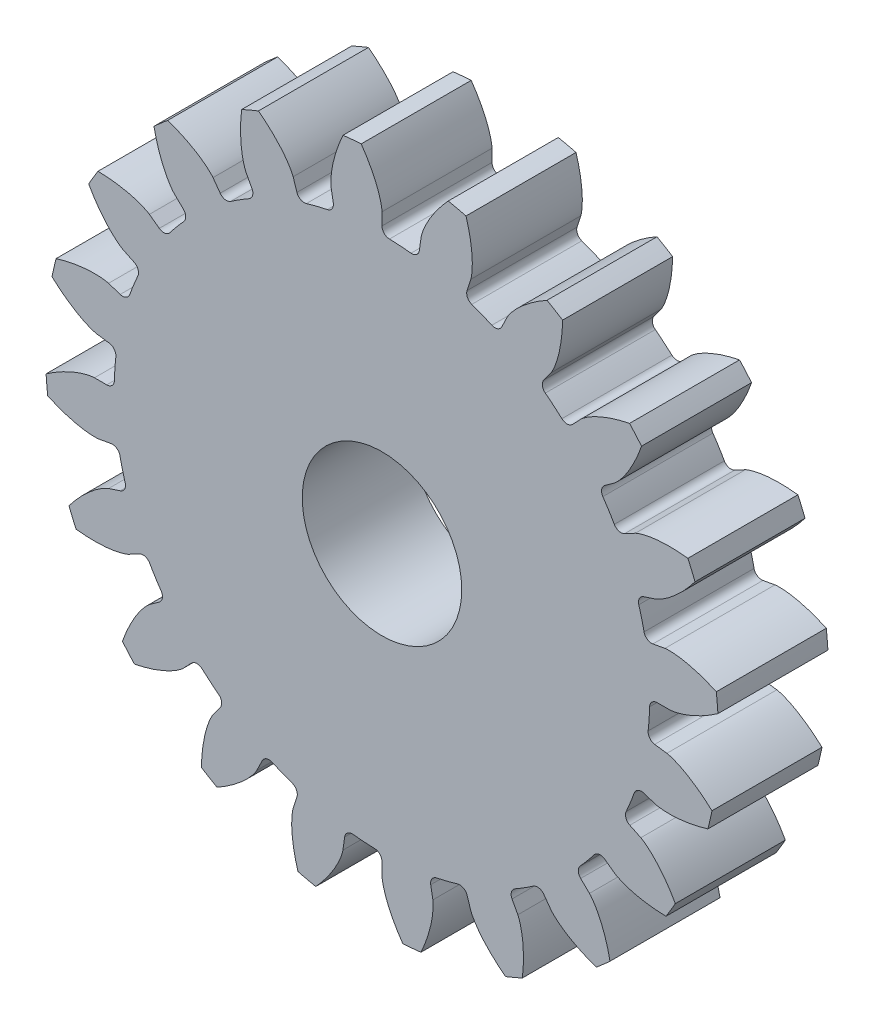
from build123d import *

# Parameters (mm, degrees)
BOSS_EXTRUDE3_DEPTH       = 4
FILLET1_R                 = 0.278125
CIRPATTERN8_COUNT         = 20
CIRPATTERN8_COPY_1_DEPTH  = 4
CIRPATTERN8_COPY_2_DEPTH  = 4
CIRPATTERN8_COPY_3_DEPTH  = 4
CIRPATTERN8_COPY_4_DEPTH  = 4
CIRPATTERN8_COPY_5_DEPTH  = 4
CIRPATTERN8_COPY_6_DEPTH  = 4
CIRPATTERN8_COPY_7_DEPTH  = 4
CIRPATTERN8_COPY_8_DEPTH  = 4
CIRPATTERN8_COPY_9_DEPTH  = 4
CIRPATTERN8_COPY_10_DEPTH = 4
CIRPATTERN8_COPY_11_DEPTH = 4
CIRPATTERN8_COPY_12_DEPTH = 4
CIRPATTERN8_COPY_13_DEPTH = 4
CIRPATTERN8_COPY_14_DEPTH = 4
CIRPATTERN8_COPY_15_DEPTH = 4
CIRPATTERN8_COPY_16_DEPTH = 4
CIRPATTERN8_COPY_17_DEPTH = 4
CIRPATTERN8_COPY_18_DEPTH = 4
CIRPATTERN8_COPY_19_DEPTH = 4
FILLET1_OF_CIRPATTERN8_R  = 0.278125
SKETCH3_R                 = 2.9
CUT_EXTRUDE2_DEPTH        = 5.0000001


with BuildPart() as part:
    # Sketch1 → Boss-Extrude3 (new body)
    with BuildSketch(Plane.XY):
        with BuildLine():
            Line((9.734375, 0), (10.454080406, 0))
            add(Edge.make_bspline(
                [(10.454080406, 0), (10.461809141, 0.000163554), (10.48346946, 0.00112842), (10.524328883, 0.004950284), (10.590725843, 0.014014033), (10.674812946, 0.0297017), (10.782700919, 0.054699934), (10.908582693, 0.090177148), (11.045409754, 0.135423901), (11.192393304, 0.191325941), (11.337182026, 0.252938931), (11.479722698, 0.319767641), (11.619896721, 0.391139023), (11.787363934, 0.483173443), (11.953826699, 0.582713105), (12.083883515, 0.667078153), (12.179202273, 0.732235691), (12.21409259, 0.756537141)],
                knots=[0, 0, 0, 0, 0, 0.005376748, 0.015083688, 0.02853182, 0.046610139, 0.064854849, 0.092110525, 0.119476175, 0.146842495, 0.174208853, 0.201574955, 0.228941013, 0.256307345, 0.307035032, 0.336624535, 0.336624535, 0.336624535, 0.336624535, 0.336624535], degree=4))
            ThreePointArc((12.21409259, 0.756537141), (12.202725609, 0.921896939), (12.189120016, 1.087087613))
            Line((12.189120016, 1.087087613), (9.695890922, 0.864728783))
            ThreePointArc((9.695890922, 0.864728783), (9.724749221, 0.432792356), (9.734375, 0))
        make_face()
        with BuildLine():
            ThreePointArc((-9.695890922, -0.864728783), (0.432792356, -9.724749221), (9.734375, 0))
            ThreePointArc((9.734375, 0), (9.724749221, 0.432792356), (9.695890922, 0.864728783))
            Line((9.695890922, 0.864728783), (-9.695890922, -0.864728783))
        make_face()
        with BuildLine():
            Line((-9.695890922, -0.864728783), (9.695890922, 0.864728783))
            ThreePointArc((9.695890922, 0.864728783), (-0.864728783, 9.695890922), (-9.695890922, -0.864728783))
        make_face()
    boss_extrude3 = extrude(amount=BOSS_EXTRUDE3_DEPTH)

    # Mirror2: Boss-Extrude3 across plane
    add(boss_extrude3.mirror(Plane(origin=(0, 0, 4), x_dir=(0, 0, 1), z_dir=(0.088832491, -0.996046579, 0))))

    # Fillet1
    fillet1_edges = [part.edges().sort_by_distance(p)[0] for p in [
        (9.734375, 0, 2),
        (9.580742976, 1.722620293, 2),
    ]]
    fillet(fillet1_edges, radius=FILLET1_R)

    # CirPattern8: Boss-Extrude3 ×20 about axis
    cirpattern8_axis = Axis((0, 0, 4), (0, 0, -1))
    for i in range(1, CIRPATTERN8_COUNT):
        add(boss_extrude3.rotate(cirpattern8_axis, i * 360 / CIRPATTERN8_COUNT))

    # CirPattern8 copy 1 sketch → CirPattern8 copy 1 (add)
    with BuildSketch(Plane(origin=(0, 0, 0), x_dir=(0.99073099, -0.135838525, 0), z_dir=(0, 0, 1))):
        with BuildLine():
            Line((9.734375, 0), (10.454080406, 0))
            add(Edge.make_bspline(
                [(10.454080406, 0), (10.461809141, -0.000163554), (10.48346946, -0.00112842), (10.524328883, -0.004950284), (10.590725843, -0.014014033), (10.674812946, -0.0297017), (10.782700919, -0.054699934), (10.908582693, -0.090177148), (11.045409754, -0.135423901), (11.192393304, -0.191325941), (11.337182026, -0.252938931), (11.479722698, -0.319767641), (11.619896721, -0.391139023), (11.787363934, -0.483173443), (11.953826699, -0.582713105), (12.083883515, -0.667078153), (12.179202273, -0.732235691), (12.21409259, -0.756537141)],
                knots=[0, 0, 0, 0, 0, 0.005376748, 0.015083688, 0.02853182, 0.046610139, 0.064854849, 0.092110525, 0.119476175, 0.146842495, 0.174208853, 0.201574955, 0.228941013, 0.256307345, 0.307035032, 0.336624535, 0.336624535, 0.336624535, 0.336624535, 0.336624535], degree=4))
            ThreePointArc((12.21409259, -0.756537141), (12.202725609, -0.921896939), (12.189120016, -1.087087613))
            Line((12.189120016, -1.087087613), (9.695890922, -0.864728783))
            ThreePointArc((9.695890922, -0.864728783), (9.724749221, -0.432792356), (9.734375, 0))
        make_face()
        with BuildLine():
            ThreePointArc((-9.695890922, 0.864728783), (0.432792356, 9.724749221), (9.734375, 0))
            ThreePointArc((9.734375, 0), (9.724749221, -0.432792356), (9.695890922, -0.864728783))
            Line((9.695890922, -0.864728783), (-9.695890922, 0.864728783))
        make_face()
        with BuildLine():
            Line((-9.695890922, 0.864728783), (9.695890922, -0.864728783))
            ThreePointArc((9.695890922, -0.864728783), (-0.864728783, -9.695890922), (-9.695890922, 0.864728783))
        make_face()
    extrude(amount=CIRPATTERN8_COPY_1_DEPTH)

    # CirPattern8 copy 2 sketch → CirPattern8 copy 2 (add)
    with BuildSketch(Plane(origin=(0, 0, 0), x_dir=(0.900264751, -0.435342827, 0), z_dir=(0, 0, 1))):
        with BuildLine():
            Line((9.734375, 0), (10.454080406, 0))
            add(Edge.make_bspline(
                [(10.454080406, 0), (10.461809141, -0.000163554), (10.48346946, -0.00112842), (10.524328883, -0.004950284), (10.590725843, -0.014014033), (10.674812946, -0.0297017), (10.782700919, -0.054699934), (10.908582693, -0.090177148), (11.045409754, -0.135423901), (11.192393304, -0.191325941), (11.337182026, -0.252938931), (11.479722698, -0.319767641), (11.619896721, -0.391139023), (11.787363934, -0.483173443), (11.953826699, -0.582713105), (12.083883515, -0.667078153), (12.179202273, -0.732235691), (12.21409259, -0.756537141)],
                knots=[0, 0, 0, 0, 0, 0.005376748, 0.015083688, 0.02853182, 0.046610139, 0.064854849, 0.092110525, 0.119476175, 0.146842495, 0.174208853, 0.201574955, 0.228941013, 0.256307345, 0.307035032, 0.336624535, 0.336624535, 0.336624535, 0.336624535, 0.336624535], degree=4))
            ThreePointArc((12.21409259, -0.756537141), (12.202725609, -0.921896939), (12.189120016, -1.087087613))
            Line((12.189120016, -1.087087613), (9.695890922, -0.864728783))
            ThreePointArc((9.695890922, -0.864728783), (9.724749221, -0.432792356), (9.734375, 0))
        make_face()
        with BuildLine():
            ThreePointArc((-9.695890922, 0.864728783), (0.432792356, 9.724749221), (9.734375, 0))
            ThreePointArc((9.734375, 0), (9.724749221, -0.432792356), (9.695890922, -0.864728783))
            Line((9.695890922, -0.864728783), (-9.695890922, 0.864728783))
        make_face()
        with BuildLine():
            Line((-9.695890922, 0.864728783), (9.695890922, -0.864728783))
            ThreePointArc((9.695890922, -0.864728783), (-0.864728783, -9.695890922), (-9.695890922, 0.864728783))
        make_face()
    extrude(amount=CIRPATTERN8_COPY_2_DEPTH)

    # CirPattern8 copy 3 sketch → CirPattern8 copy 3 (add)
    with BuildSketch(Plane(origin=(0, 0, 0), x_dir=(0.721674326, -0.69223274, 0), z_dir=(0, 0, 1))):
        with BuildLine():
            Line((9.734375, 0), (10.454080406, 0))
            add(Edge.make_bspline(
                [(10.454080406, 0), (10.461809141, -0.000163554), (10.48346946, -0.00112842), (10.524328883, -0.004950284), (10.590725843, -0.014014033), (10.674812946, -0.0297017), (10.782700919, -0.054699934), (10.908582693, -0.090177148), (11.045409754, -0.135423901), (11.192393304, -0.191325941), (11.337182026, -0.252938931), (11.479722698, -0.319767641), (11.619896721, -0.391139023), (11.787363934, -0.483173443), (11.953826699, -0.582713105), (12.083883515, -0.667078153), (12.179202273, -0.732235691), (12.21409259, -0.756537141)],
                knots=[0, 0, 0, 0, 0, 0.005376748, 0.015083688, 0.02853182, 0.046610139, 0.064854849, 0.092110525, 0.119476175, 0.146842495, 0.174208853, 0.201574955, 0.228941013, 0.256307345, 0.307035032, 0.336624535, 0.336624535, 0.336624535, 0.336624535, 0.336624535], degree=4))
            ThreePointArc((12.21409259, -0.756537141), (12.202725609, -0.921896939), (12.189120016, -1.087087613))
            Line((12.189120016, -1.087087613), (9.695890922, -0.864728783))
            ThreePointArc((9.695890922, -0.864728783), (9.724749221, -0.432792356), (9.734375, 0))
        make_face()
        with BuildLine():
            ThreePointArc((-9.695890922, 0.864728783), (0.432792356, 9.724749221), (9.734375, 0))
            ThreePointArc((9.734375, 0), (9.724749221, -0.432792356), (9.695890922, -0.864728783))
            Line((9.695890922, -0.864728783), (-9.695890922, 0.864728783))
        make_face()
        with BuildLine():
            Line((-9.695890922, 0.864728783), (9.695890922, -0.864728783))
            ThreePointArc((9.695890922, -0.864728783), (-0.864728783, -9.695890922), (-9.695890922, 0.864728783))
        make_face()
    extrude(amount=CIRPATTERN8_COPY_3_DEPTH)

    # CirPattern8 copy 4 sketch → CirPattern8 copy 4 (add)
    with BuildSketch(Plane(origin=(0, 0, 0), x_dir=(0.47244139, -0.88136209, 0), z_dir=(0, 0, 1))):
        with BuildLine():
            Line((9.734375, 0), (10.454080406, 0))
            add(Edge.make_bspline(
                [(10.454080406, 0), (10.461809141, -0.000163554), (10.48346946, -0.00112842), (10.524328883, -0.004950284), (10.590725843, -0.014014033), (10.674812946, -0.0297017), (10.782700919, -0.054699934), (10.908582693, -0.090177148), (11.045409754, -0.135423901), (11.192393304, -0.191325941), (11.337182026, -0.252938931), (11.479722698, -0.319767641), (11.619896721, -0.391139023), (11.787363934, -0.483173443), (11.953826699, -0.582713105), (12.083883515, -0.667078153), (12.179202273, -0.732235691), (12.21409259, -0.756537141)],
                knots=[0, 0, 0, 0, 0, 0.005376748, 0.015083688, 0.02853182, 0.046610139, 0.064854849, 0.092110525, 0.119476175, 0.146842495, 0.174208853, 0.201574955, 0.228941013, 0.256307345, 0.307035032, 0.336624535, 0.336624535, 0.336624535, 0.336624535, 0.336624535], degree=4))
            ThreePointArc((12.21409259, -0.756537141), (12.202725609, -0.921896939), (12.189120016, -1.087087613))
            Line((12.189120016, -1.087087613), (9.695890922, -0.864728783))
            ThreePointArc((9.695890922, -0.864728783), (9.724749221, -0.432792356), (9.734375, 0))
        make_face()
        with BuildLine():
            ThreePointArc((-9.695890922, 0.864728783), (0.432792356, 9.724749221), (9.734375, 0))
            ThreePointArc((9.734375, 0), (9.724749221, -0.432792356), (9.695890922, -0.864728783))
            Line((9.695890922, -0.864728783), (-9.695890922, 0.864728783))
        make_face()
        with BuildLine():
            Line((-9.695890922, 0.864728783), (9.695890922, -0.864728783))
            ThreePointArc((9.695890922, -0.864728783), (-0.864728783, -9.695890922), (-9.695890922, 0.864728783))
        make_face()
    extrude(amount=CIRPATTERN8_COPY_4_DEPTH)

    # CirPattern8 copy 5 sketch → CirPattern8 copy 5 (add)
    with BuildSketch(Plane(origin=(0, 0, 0), x_dir=(0.176962598, -0.984217577, 0), z_dir=(0, 0, 1))):
        with BuildLine():
            Line((9.734375, 0), (10.454080406, 0))
            add(Edge.make_bspline(
                [(10.454080406, 0), (10.461809141, -0.000163554), (10.48346946, -0.00112842), (10.524328883, -0.004950284), (10.590725843, -0.014014033), (10.674812946, -0.0297017), (10.782700919, -0.054699934), (10.908582693, -0.090177148), (11.045409754, -0.135423901), (11.192393304, -0.191325941), (11.337182026, -0.252938931), (11.479722698, -0.319767641), (11.619896721, -0.391139023), (11.787363934, -0.483173443), (11.953826699, -0.582713105), (12.083883515, -0.667078153), (12.179202273, -0.732235691), (12.21409259, -0.756537141)],
                knots=[0, 0, 0, 0, 0, 0.005376748, 0.015083688, 0.02853182, 0.046610139, 0.064854849, 0.092110525, 0.119476175, 0.146842495, 0.174208853, 0.201574955, 0.228941013, 0.256307345, 0.307035032, 0.336624535, 0.336624535, 0.336624535, 0.336624535, 0.336624535], degree=4))
            ThreePointArc((12.21409259, -0.756537141), (12.202725609, -0.921896939), (12.189120016, -1.087087613))
            Line((12.189120016, -1.087087613), (9.695890922, -0.864728783))
            ThreePointArc((9.695890922, -0.864728783), (9.724749221, -0.432792356), (9.734375, 0))
        make_face()
        with BuildLine():
            ThreePointArc((-9.695890922, 0.864728783), (0.432792356, 9.724749221), (9.734375, 0))
            ThreePointArc((9.734375, 0), (9.724749221, -0.432792356), (9.695890922, -0.864728783))
            Line((9.695890922, -0.864728783), (-9.695890922, 0.864728783))
        make_face()
        with BuildLine():
            Line((-9.695890922, 0.864728783), (9.695890922, -0.864728783))
            ThreePointArc((9.695890922, -0.864728783), (-0.864728783, -9.695890922), (-9.695890922, 0.864728783))
        make_face()
    extrude(amount=CIRPATTERN8_COPY_5_DEPTH)

    # CirPattern8 copy 6 sketch → CirPattern8 copy 6 (add)
    with BuildSketch(Plane(origin=(0, 0, 0), x_dir=(-0.135838525, -0.99073099, 0), z_dir=(0, 0, 1))):
        with BuildLine():
            Line((9.734375, 0), (10.454080406, 0))
            add(Edge.make_bspline(
                [(10.454080406, 0), (10.461809141, -0.000163554), (10.48346946, -0.00112842), (10.524328883, -0.004950284), (10.590725843, -0.014014033), (10.674812946, -0.0297017), (10.782700919, -0.054699934), (10.908582693, -0.090177148), (11.045409754, -0.135423901), (11.192393304, -0.191325941), (11.337182026, -0.252938931), (11.479722698, -0.319767641), (11.619896721, -0.391139023), (11.787363934, -0.483173443), (11.953826699, -0.582713105), (12.083883515, -0.667078153), (12.179202273, -0.732235691), (12.21409259, -0.756537141)],
                knots=[0, 0, 0, 0, 0, 0.005376748, 0.015083688, 0.02853182, 0.046610139, 0.064854849, 0.092110525, 0.119476175, 0.146842495, 0.174208853, 0.201574955, 0.228941013, 0.256307345, 0.307035032, 0.336624535, 0.336624535, 0.336624535, 0.336624535, 0.336624535], degree=4))
            ThreePointArc((12.21409259, -0.756537141), (12.202725609, -0.921896939), (12.189120016, -1.087087613))
            Line((12.189120016, -1.087087613), (9.695890922, -0.864728783))
            ThreePointArc((9.695890922, -0.864728783), (9.724749221, -0.432792356), (9.734375, 0))
        make_face()
        with BuildLine():
            ThreePointArc((-9.695890922, 0.864728783), (0.432792356, 9.724749221), (9.734375, 0))
            ThreePointArc((9.734375, 0), (9.724749221, -0.432792356), (9.695890922, -0.864728783))
            Line((9.695890922, -0.864728783), (-9.695890922, 0.864728783))
        make_face()
        with BuildLine():
            Line((-9.695890922, 0.864728783), (9.695890922, -0.864728783))
            ThreePointArc((9.695890922, -0.864728783), (-0.864728783, -9.695890922), (-9.695890922, 0.864728783))
        make_face()
    extrude(amount=CIRPATTERN8_COPY_6_DEPTH)

    # CirPattern8 copy 7 sketch → CirPattern8 copy 7 (add)
    with BuildSketch(Plane(origin=(0, 0, 0), x_dir=(-0.435342827, -0.900264751, 0), z_dir=(0, 0, 1))):
        with BuildLine():
            Line((9.734375, 0), (10.454080406, 0))
            add(Edge.make_bspline(
                [(10.454080406, 0), (10.461809141, -0.000163554), (10.48346946, -0.00112842), (10.524328883, -0.004950284), (10.590725843, -0.014014033), (10.674812946, -0.0297017), (10.782700919, -0.054699934), (10.908582693, -0.090177148), (11.045409754, -0.135423901), (11.192393304, -0.191325941), (11.337182026, -0.252938931), (11.479722698, -0.319767641), (11.619896721, -0.391139023), (11.787363934, -0.483173443), (11.953826699, -0.582713105), (12.083883515, -0.667078153), (12.179202273, -0.732235691), (12.21409259, -0.756537141)],
                knots=[0, 0, 0, 0, 0, 0.005376748, 0.015083688, 0.02853182, 0.046610139, 0.064854849, 0.092110525, 0.119476175, 0.146842495, 0.174208853, 0.201574955, 0.228941013, 0.256307345, 0.307035032, 0.336624535, 0.336624535, 0.336624535, 0.336624535, 0.336624535], degree=4))
            ThreePointArc((12.21409259, -0.756537141), (12.202725609, -0.921896939), (12.189120016, -1.087087613))
            Line((12.189120016, -1.087087613), (9.695890922, -0.864728783))
            ThreePointArc((9.695890922, -0.864728783), (9.724749221, -0.432792356), (9.734375, 0))
        make_face()
        with BuildLine():
            ThreePointArc((-9.695890922, 0.864728783), (0.432792356, 9.724749221), (9.734375, 0))
            ThreePointArc((9.734375, 0), (9.724749221, -0.432792356), (9.695890922, -0.864728783))
            Line((9.695890922, -0.864728783), (-9.695890922, 0.864728783))
        make_face()
        with BuildLine():
            Line((-9.695890922, 0.864728783), (9.695890922, -0.864728783))
            ThreePointArc((9.695890922, -0.864728783), (-0.864728783, -9.695890922), (-9.695890922, 0.864728783))
        make_face()
    extrude(amount=CIRPATTERN8_COPY_7_DEPTH)

    # CirPattern8 copy 8 sketch → CirPattern8 copy 8 (add)
    with BuildSketch(Plane(origin=(0, 0, 0), x_dir=(-0.69223274, -0.721674326, 0), z_dir=(0, 0, 1))):
        with BuildLine():
            Line((9.734375, 0), (10.454080406, 0))
            add(Edge.make_bspline(
                [(10.454080406, 0), (10.461809141, -0.000163554), (10.48346946, -0.00112842), (10.524328883, -0.004950284), (10.590725843, -0.014014033), (10.674812946, -0.0297017), (10.782700919, -0.054699934), (10.908582693, -0.090177148), (11.045409754, -0.135423901), (11.192393304, -0.191325941), (11.337182026, -0.252938931), (11.479722698, -0.319767641), (11.619896721, -0.391139023), (11.787363934, -0.483173443), (11.953826699, -0.582713105), (12.083883515, -0.667078153), (12.179202273, -0.732235691), (12.21409259, -0.756537141)],
                knots=[0, 0, 0, 0, 0, 0.005376748, 0.015083688, 0.02853182, 0.046610139, 0.064854849, 0.092110525, 0.119476175, 0.146842495, 0.174208853, 0.201574955, 0.228941013, 0.256307345, 0.307035032, 0.336624535, 0.336624535, 0.336624535, 0.336624535, 0.336624535], degree=4))
            ThreePointArc((12.21409259, -0.756537141), (12.202725609, -0.921896939), (12.189120016, -1.087087613))
            Line((12.189120016, -1.087087613), (9.695890922, -0.864728783))
            ThreePointArc((9.695890922, -0.864728783), (9.724749221, -0.432792356), (9.734375, 0))
        make_face()
        with BuildLine():
            ThreePointArc((-9.695890922, 0.864728783), (0.432792356, 9.724749221), (9.734375, 0))
            ThreePointArc((9.734375, 0), (9.724749221, -0.432792356), (9.695890922, -0.864728783))
            Line((9.695890922, -0.864728783), (-9.695890922, 0.864728783))
        make_face()
        with BuildLine():
            Line((-9.695890922, 0.864728783), (9.695890922, -0.864728783))
            ThreePointArc((9.695890922, -0.864728783), (-0.864728783, -9.695890922), (-9.695890922, 0.864728783))
        make_face()
    extrude(amount=CIRPATTERN8_COPY_8_DEPTH)

    # CirPattern8 copy 9 sketch → CirPattern8 copy 9 (add)
    with BuildSketch(Plane(origin=(0, 0, 0), x_dir=(-0.88136209, -0.47244139, 0), z_dir=(0, 0, 1))):
        with BuildLine():
            Line((9.734375, 0), (10.454080406, 0))
            add(Edge.make_bspline(
                [(10.454080406, 0), (10.461809141, -0.000163554), (10.48346946, -0.00112842), (10.524328883, -0.004950284), (10.590725843, -0.014014033), (10.674812946, -0.0297017), (10.782700919, -0.054699934), (10.908582693, -0.090177148), (11.045409754, -0.135423901), (11.192393304, -0.191325941), (11.337182026, -0.252938931), (11.479722698, -0.319767641), (11.619896721, -0.391139023), (11.787363934, -0.483173443), (11.953826699, -0.582713105), (12.083883515, -0.667078153), (12.179202273, -0.732235691), (12.21409259, -0.756537141)],
                knots=[0, 0, 0, 0, 0, 0.005376748, 0.015083688, 0.02853182, 0.046610139, 0.064854849, 0.092110525, 0.119476175, 0.146842495, 0.174208853, 0.201574955, 0.228941013, 0.256307345, 0.307035032, 0.336624535, 0.336624535, 0.336624535, 0.336624535, 0.336624535], degree=4))
            ThreePointArc((12.21409259, -0.756537141), (12.202725609, -0.921896939), (12.189120016, -1.087087613))
            Line((12.189120016, -1.087087613), (9.695890922, -0.864728783))
            ThreePointArc((9.695890922, -0.864728783), (9.724749221, -0.432792356), (9.734375, 0))
        make_face()
        with BuildLine():
            ThreePointArc((-9.695890922, 0.864728783), (0.432792356, 9.724749221), (9.734375, 0))
            ThreePointArc((9.734375, 0), (9.724749221, -0.432792356), (9.695890922, -0.864728783))
            Line((9.695890922, -0.864728783), (-9.695890922, 0.864728783))
        make_face()
        with BuildLine():
            Line((-9.695890922, 0.864728783), (9.695890922, -0.864728783))
            ThreePointArc((9.695890922, -0.864728783), (-0.864728783, -9.695890922), (-9.695890922, 0.864728783))
        make_face()
    extrude(amount=CIRPATTERN8_COPY_9_DEPTH)

    # CirPattern8 copy 10 sketch → CirPattern8 copy 10 (add)
    with BuildSketch(Plane(origin=(0, 0, 0), x_dir=(-0.984217577, -0.176962598, 0), z_dir=(0, 0, 1))):
        with BuildLine():
            Line((9.734375, 0), (10.454080406, 0))
            add(Edge.make_bspline(
                [(10.454080406, 0), (10.461809141, -0.000163554), (10.48346946, -0.00112842), (10.524328883, -0.004950284), (10.590725843, -0.014014033), (10.674812946, -0.0297017), (10.782700919, -0.054699934), (10.908582693, -0.090177148), (11.045409754, -0.135423901), (11.192393304, -0.191325941), (11.337182026, -0.252938931), (11.479722698, -0.319767641), (11.619896721, -0.391139023), (11.787363934, -0.483173443), (11.953826699, -0.582713105), (12.083883515, -0.667078153), (12.179202273, -0.732235691), (12.21409259, -0.756537141)],
                knots=[0, 0, 0, 0, 0, 0.005376748, 0.015083688, 0.02853182, 0.046610139, 0.064854849, 0.092110525, 0.119476175, 0.146842495, 0.174208853, 0.201574955, 0.228941013, 0.256307345, 0.307035032, 0.336624535, 0.336624535, 0.336624535, 0.336624535, 0.336624535], degree=4))
            ThreePointArc((12.21409259, -0.756537141), (12.202725609, -0.921896939), (12.189120016, -1.087087613))
            Line((12.189120016, -1.087087613), (9.695890922, -0.864728783))
            ThreePointArc((9.695890922, -0.864728783), (9.724749221, -0.432792356), (9.734375, 0))
        make_face()
        with BuildLine():
            ThreePointArc((-9.695890922, 0.864728783), (0.432792356, 9.724749221), (9.734375, 0))
            ThreePointArc((9.734375, 0), (9.724749221, -0.432792356), (9.695890922, -0.864728783))
            Line((9.695890922, -0.864728783), (-9.695890922, 0.864728783))
        make_face()
        with BuildLine():
            Line((-9.695890922, 0.864728783), (9.695890922, -0.864728783))
            ThreePointArc((9.695890922, -0.864728783), (-0.864728783, -9.695890922), (-9.695890922, 0.864728783))
        make_face()
    extrude(amount=CIRPATTERN8_COPY_10_DEPTH)

    # CirPattern8 copy 11 sketch → CirPattern8 copy 11 (add)
    with BuildSketch(Plane(origin=(0, 0, 0), x_dir=(-0.99073099, 0.135838525, 0), z_dir=(0, 0, 1))):
        with BuildLine():
            Line((9.734375, 0), (10.454080406, 0))
            add(Edge.make_bspline(
                [(10.454080406, 0), (10.461809141, -0.000163554), (10.48346946, -0.00112842), (10.524328883, -0.004950284), (10.590725843, -0.014014033), (10.674812946, -0.0297017), (10.782700919, -0.054699934), (10.908582693, -0.090177148), (11.045409754, -0.135423901), (11.192393304, -0.191325941), (11.337182026, -0.252938931), (11.479722698, -0.319767641), (11.619896721, -0.391139023), (11.787363934, -0.483173443), (11.953826699, -0.582713105), (12.083883515, -0.667078153), (12.179202273, -0.732235691), (12.21409259, -0.756537141)],
                knots=[0, 0, 0, 0, 0, 0.005376748, 0.015083688, 0.02853182, 0.046610139, 0.064854849, 0.092110525, 0.119476175, 0.146842495, 0.174208853, 0.201574955, 0.228941013, 0.256307345, 0.307035032, 0.336624535, 0.336624535, 0.336624535, 0.336624535, 0.336624535], degree=4))
            ThreePointArc((12.21409259, -0.756537141), (12.202725609, -0.921896939), (12.189120016, -1.087087613))
            Line((12.189120016, -1.087087613), (9.695890922, -0.864728783))
            ThreePointArc((9.695890922, -0.864728783), (9.724749221, -0.432792356), (9.734375, 0))
        make_face()
        with BuildLine():
            ThreePointArc((-9.695890922, 0.864728783), (0.432792356, 9.724749221), (9.734375, 0))
            ThreePointArc((9.734375, 0), (9.724749221, -0.432792356), (9.695890922, -0.864728783))
            Line((9.695890922, -0.864728783), (-9.695890922, 0.864728783))
        make_face()
        with BuildLine():
            Line((-9.695890922, 0.864728783), (9.695890922, -0.864728783))
            ThreePointArc((9.695890922, -0.864728783), (-0.864728783, -9.695890922), (-9.695890922, 0.864728783))
        make_face()
    extrude(amount=CIRPATTERN8_COPY_11_DEPTH)

    # CirPattern8 copy 12 sketch → CirPattern8 copy 12 (add)
    with BuildSketch(Plane(origin=(0, 0, 0), x_dir=(-0.900264751, 0.435342827, 0), z_dir=(0, 0, 1))):
        with BuildLine():
            Line((9.734375, 0), (10.454080406, 0))
            add(Edge.make_bspline(
                [(10.454080406, 0), (10.461809141, -0.000163554), (10.48346946, -0.00112842), (10.524328883, -0.004950284), (10.590725843, -0.014014033), (10.674812946, -0.0297017), (10.782700919, -0.054699934), (10.908582693, -0.090177148), (11.045409754, -0.135423901), (11.192393304, -0.191325941), (11.337182026, -0.252938931), (11.479722698, -0.319767641), (11.619896721, -0.391139023), (11.787363934, -0.483173443), (11.953826699, -0.582713105), (12.083883515, -0.667078153), (12.179202273, -0.732235691), (12.21409259, -0.756537141)],
                knots=[0, 0, 0, 0, 0, 0.005376748, 0.015083688, 0.02853182, 0.046610139, 0.064854849, 0.092110525, 0.119476175, 0.146842495, 0.174208853, 0.201574955, 0.228941013, 0.256307345, 0.307035032, 0.336624535, 0.336624535, 0.336624535, 0.336624535, 0.336624535], degree=4))
            ThreePointArc((12.21409259, -0.756537141), (12.202725609, -0.921896939), (12.189120016, -1.087087613))
            Line((12.189120016, -1.087087613), (9.695890922, -0.864728783))
            ThreePointArc((9.695890922, -0.864728783), (9.724749221, -0.432792356), (9.734375, 0))
        make_face()
        with BuildLine():
            ThreePointArc((-9.695890922, 0.864728783), (0.432792356, 9.724749221), (9.734375, 0))
            ThreePointArc((9.734375, 0), (9.724749221, -0.432792356), (9.695890922, -0.864728783))
            Line((9.695890922, -0.864728783), (-9.695890922, 0.864728783))
        make_face()
        with BuildLine():
            Line((-9.695890922, 0.864728783), (9.695890922, -0.864728783))
            ThreePointArc((9.695890922, -0.864728783), (-0.864728783, -9.695890922), (-9.695890922, 0.864728783))
        make_face()
    extrude(amount=CIRPATTERN8_COPY_12_DEPTH)

    # CirPattern8 copy 13 sketch → CirPattern8 copy 13 (add)
    with BuildSketch(Plane(origin=(0, 0, 0), x_dir=(-0.721674326, 0.69223274, 0), z_dir=(0, 0, 1))):
        with BuildLine():
            Line((9.734375, 0), (10.454080406, 0))
            add(Edge.make_bspline(
                [(10.454080406, 0), (10.461809141, -0.000163554), (10.48346946, -0.00112842), (10.524328883, -0.004950284), (10.590725843, -0.014014033), (10.674812946, -0.0297017), (10.782700919, -0.054699934), (10.908582693, -0.090177148), (11.045409754, -0.135423901), (11.192393304, -0.191325941), (11.337182026, -0.252938931), (11.479722698, -0.319767641), (11.619896721, -0.391139023), (11.787363934, -0.483173443), (11.953826699, -0.582713105), (12.083883515, -0.667078153), (12.179202273, -0.732235691), (12.21409259, -0.756537141)],
                knots=[0, 0, 0, 0, 0, 0.005376748, 0.015083688, 0.02853182, 0.046610139, 0.064854849, 0.092110525, 0.119476175, 0.146842495, 0.174208853, 0.201574955, 0.228941013, 0.256307345, 0.307035032, 0.336624535, 0.336624535, 0.336624535, 0.336624535, 0.336624535], degree=4))
            ThreePointArc((12.21409259, -0.756537141), (12.202725609, -0.921896939), (12.189120016, -1.087087613))
            Line((12.189120016, -1.087087613), (9.695890922, -0.864728783))
            ThreePointArc((9.695890922, -0.864728783), (9.724749221, -0.432792356), (9.734375, 0))
        make_face()
        with BuildLine():
            ThreePointArc((-9.695890922, 0.864728783), (0.432792356, 9.724749221), (9.734375, 0))
            ThreePointArc((9.734375, 0), (9.724749221, -0.432792356), (9.695890922, -0.864728783))
            Line((9.695890922, -0.864728783), (-9.695890922, 0.864728783))
        make_face()
        with BuildLine():
            Line((-9.695890922, 0.864728783), (9.695890922, -0.864728783))
            ThreePointArc((9.695890922, -0.864728783), (-0.864728783, -9.695890922), (-9.695890922, 0.864728783))
        make_face()
    extrude(amount=CIRPATTERN8_COPY_13_DEPTH)

    # CirPattern8 copy 14 sketch → CirPattern8 copy 14 (add)
    with BuildSketch(Plane(origin=(0, 0, 0), x_dir=(-0.47244139, 0.88136209, 0), z_dir=(0, 0, 1))):
        with BuildLine():
            Line((9.734375, 0), (10.454080406, 0))
            add(Edge.make_bspline(
                [(10.454080406, 0), (10.461809141, -0.000163554), (10.48346946, -0.00112842), (10.524328883, -0.004950284), (10.590725843, -0.014014033), (10.674812946, -0.0297017), (10.782700919, -0.054699934), (10.908582693, -0.090177148), (11.045409754, -0.135423901), (11.192393304, -0.191325941), (11.337182026, -0.252938931), (11.479722698, -0.319767641), (11.619896721, -0.391139023), (11.787363934, -0.483173443), (11.953826699, -0.582713105), (12.083883515, -0.667078153), (12.179202273, -0.732235691), (12.21409259, -0.756537141)],
                knots=[0, 0, 0, 0, 0, 0.005376748, 0.015083688, 0.02853182, 0.046610139, 0.064854849, 0.092110525, 0.119476175, 0.146842495, 0.174208853, 0.201574955, 0.228941013, 0.256307345, 0.307035032, 0.336624535, 0.336624535, 0.336624535, 0.336624535, 0.336624535], degree=4))
            ThreePointArc((12.21409259, -0.756537141), (12.202725609, -0.921896939), (12.189120016, -1.087087613))
            Line((12.189120016, -1.087087613), (9.695890922, -0.864728783))
            ThreePointArc((9.695890922, -0.864728783), (9.724749221, -0.432792356), (9.734375, 0))
        make_face()
        with BuildLine():
            ThreePointArc((-9.695890922, 0.864728783), (0.432792356, 9.724749221), (9.734375, 0))
            ThreePointArc((9.734375, 0), (9.724749221, -0.432792356), (9.695890922, -0.864728783))
            Line((9.695890922, -0.864728783), (-9.695890922, 0.864728783))
        make_face()
        with BuildLine():
            Line((-9.695890922, 0.864728783), (9.695890922, -0.864728783))
            ThreePointArc((9.695890922, -0.864728783), (-0.864728783, -9.695890922), (-9.695890922, 0.864728783))
        make_face()
    extrude(amount=CIRPATTERN8_COPY_14_DEPTH)

    # CirPattern8 copy 15 sketch → CirPattern8 copy 15 (add)
    with BuildSketch(Plane(origin=(0, 0, 0), x_dir=(-0.176962598, 0.984217577, 0), z_dir=(0, 0, 1))):
        with BuildLine():
            Line((9.734375, 0), (10.454080406, 0))
            add(Edge.make_bspline(
                [(10.454080406, 0), (10.461809141, -0.000163554), (10.48346946, -0.00112842), (10.524328883, -0.004950284), (10.590725843, -0.014014033), (10.674812946, -0.0297017), (10.782700919, -0.054699934), (10.908582693, -0.090177148), (11.045409754, -0.135423901), (11.192393304, -0.191325941), (11.337182026, -0.252938931), (11.479722698, -0.319767641), (11.619896721, -0.391139023), (11.787363934, -0.483173443), (11.953826699, -0.582713105), (12.083883515, -0.667078153), (12.179202273, -0.732235691), (12.21409259, -0.756537141)],
                knots=[0, 0, 0, 0, 0, 0.005376748, 0.015083688, 0.02853182, 0.046610139, 0.064854849, 0.092110525, 0.119476175, 0.146842495, 0.174208853, 0.201574955, 0.228941013, 0.256307345, 0.307035032, 0.336624535, 0.336624535, 0.336624535, 0.336624535, 0.336624535], degree=4))
            ThreePointArc((12.21409259, -0.756537141), (12.202725609, -0.921896939), (12.189120016, -1.087087613))
            Line((12.189120016, -1.087087613), (9.695890922, -0.864728783))
            ThreePointArc((9.695890922, -0.864728783), (9.724749221, -0.432792356), (9.734375, 0))
        make_face()
        with BuildLine():
            ThreePointArc((-9.695890922, 0.864728783), (0.432792356, 9.724749221), (9.734375, 0))
            ThreePointArc((9.734375, 0), (9.724749221, -0.432792356), (9.695890922, -0.864728783))
            Line((9.695890922, -0.864728783), (-9.695890922, 0.864728783))
        make_face()
        with BuildLine():
            Line((-9.695890922, 0.864728783), (9.695890922, -0.864728783))
            ThreePointArc((9.695890922, -0.864728783), (-0.864728783, -9.695890922), (-9.695890922, 0.864728783))
        make_face()
    extrude(amount=CIRPATTERN8_COPY_15_DEPTH)

    # CirPattern8 copy 16 sketch → CirPattern8 copy 16 (add)
    with BuildSketch(Plane(origin=(0, 0, 0), x_dir=(0.135838525, 0.99073099, 0), z_dir=(0, 0, 1))):
        with BuildLine():
            Line((9.734375, 0), (10.454080406, 0))
            add(Edge.make_bspline(
                [(10.454080406, 0), (10.461809141, -0.000163554), (10.48346946, -0.00112842), (10.524328883, -0.004950284), (10.590725843, -0.014014033), (10.674812946, -0.0297017), (10.782700919, -0.054699934), (10.908582693, -0.090177148), (11.045409754, -0.135423901), (11.192393304, -0.191325941), (11.337182026, -0.252938931), (11.479722698, -0.319767641), (11.619896721, -0.391139023), (11.787363934, -0.483173443), (11.953826699, -0.582713105), (12.083883515, -0.667078153), (12.179202273, -0.732235691), (12.21409259, -0.756537141)],
                knots=[0, 0, 0, 0, 0, 0.005376748, 0.015083688, 0.02853182, 0.046610139, 0.064854849, 0.092110525, 0.119476175, 0.146842495, 0.174208853, 0.201574955, 0.228941013, 0.256307345, 0.307035032, 0.336624535, 0.336624535, 0.336624535, 0.336624535, 0.336624535], degree=4))
            ThreePointArc((12.21409259, -0.756537141), (12.202725609, -0.921896939), (12.189120016, -1.087087613))
            Line((12.189120016, -1.087087613), (9.695890922, -0.864728783))
            ThreePointArc((9.695890922, -0.864728783), (9.724749221, -0.432792356), (9.734375, 0))
        make_face()
        with BuildLine():
            ThreePointArc((-9.695890922, 0.864728783), (0.432792356, 9.724749221), (9.734375, 0))
            ThreePointArc((9.734375, 0), (9.724749221, -0.432792356), (9.695890922, -0.864728783))
            Line((9.695890922, -0.864728783), (-9.695890922, 0.864728783))
        make_face()
        with BuildLine():
            Line((-9.695890922, 0.864728783), (9.695890922, -0.864728783))
            ThreePointArc((9.695890922, -0.864728783), (-0.864728783, -9.695890922), (-9.695890922, 0.864728783))
        make_face()
    extrude(amount=CIRPATTERN8_COPY_16_DEPTH)

    # CirPattern8 copy 17 sketch → CirPattern8 copy 17 (add)
    with BuildSketch(Plane(origin=(0, 0, 0), x_dir=(0.435342827, 0.900264751, 0), z_dir=(0, 0, 1))):
        with BuildLine():
            Line((9.734375, 0), (10.454080406, 0))
            add(Edge.make_bspline(
                [(10.454080406, 0), (10.461809141, -0.000163554), (10.48346946, -0.00112842), (10.524328883, -0.004950284), (10.590725843, -0.014014033), (10.674812946, -0.0297017), (10.782700919, -0.054699934), (10.908582693, -0.090177148), (11.045409754, -0.135423901), (11.192393304, -0.191325941), (11.337182026, -0.252938931), (11.479722698, -0.319767641), (11.619896721, -0.391139023), (11.787363934, -0.483173443), (11.953826699, -0.582713105), (12.083883515, -0.667078153), (12.179202273, -0.732235691), (12.21409259, -0.756537141)],
                knots=[0, 0, 0, 0, 0, 0.005376748, 0.015083688, 0.02853182, 0.046610139, 0.064854849, 0.092110525, 0.119476175, 0.146842495, 0.174208853, 0.201574955, 0.228941013, 0.256307345, 0.307035032, 0.336624535, 0.336624535, 0.336624535, 0.336624535, 0.336624535], degree=4))
            ThreePointArc((12.21409259, -0.756537141), (12.202725609, -0.921896939), (12.189120016, -1.087087613))
            Line((12.189120016, -1.087087613), (9.695890922, -0.864728783))
            ThreePointArc((9.695890922, -0.864728783), (9.724749221, -0.432792356), (9.734375, 0))
        make_face()
        with BuildLine():
            ThreePointArc((-9.695890922, 0.864728783), (0.432792356, 9.724749221), (9.734375, 0))
            ThreePointArc((9.734375, 0), (9.724749221, -0.432792356), (9.695890922, -0.864728783))
            Line((9.695890922, -0.864728783), (-9.695890922, 0.864728783))
        make_face()
        with BuildLine():
            Line((-9.695890922, 0.864728783), (9.695890922, -0.864728783))
            ThreePointArc((9.695890922, -0.864728783), (-0.864728783, -9.695890922), (-9.695890922, 0.864728783))
        make_face()
    extrude(amount=CIRPATTERN8_COPY_17_DEPTH)

    # CirPattern8 copy 18 sketch → CirPattern8 copy 18 (add)
    with BuildSketch(Plane(origin=(0, 0, 0), x_dir=(0.69223274, 0.721674326, 0), z_dir=(0, 0, 1))):
        with BuildLine():
            Line((9.734375, 0), (10.454080406, 0))
            add(Edge.make_bspline(
                [(10.454080406, 0), (10.461809141, -0.000163554), (10.48346946, -0.00112842), (10.524328883, -0.004950284), (10.590725843, -0.014014033), (10.674812946, -0.0297017), (10.782700919, -0.054699934), (10.908582693, -0.090177148), (11.045409754, -0.135423901), (11.192393304, -0.191325941), (11.337182026, -0.252938931), (11.479722698, -0.319767641), (11.619896721, -0.391139023), (11.787363934, -0.483173443), (11.953826699, -0.582713105), (12.083883515, -0.667078153), (12.179202273, -0.732235691), (12.21409259, -0.756537141)],
                knots=[0, 0, 0, 0, 0, 0.005376748, 0.015083688, 0.02853182, 0.046610139, 0.064854849, 0.092110525, 0.119476175, 0.146842495, 0.174208853, 0.201574955, 0.228941013, 0.256307345, 0.307035032, 0.336624535, 0.336624535, 0.336624535, 0.336624535, 0.336624535], degree=4))
            ThreePointArc((12.21409259, -0.756537141), (12.202725609, -0.921896939), (12.189120016, -1.087087613))
            Line((12.189120016, -1.087087613), (9.695890922, -0.864728783))
            ThreePointArc((9.695890922, -0.864728783), (9.724749221, -0.432792356), (9.734375, 0))
        make_face()
        with BuildLine():
            ThreePointArc((-9.695890922, 0.864728783), (0.432792356, 9.724749221), (9.734375, 0))
            ThreePointArc((9.734375, 0), (9.724749221, -0.432792356), (9.695890922, -0.864728783))
            Line((9.695890922, -0.864728783), (-9.695890922, 0.864728783))
        make_face()
        with BuildLine():
            Line((-9.695890922, 0.864728783), (9.695890922, -0.864728783))
            ThreePointArc((9.695890922, -0.864728783), (-0.864728783, -9.695890922), (-9.695890922, 0.864728783))
        make_face()
    extrude(amount=CIRPATTERN8_COPY_18_DEPTH)

    # CirPattern8 copy 19 sketch → CirPattern8 copy 19 (add)
    with BuildSketch(Plane(origin=(0, 0, 0), x_dir=(0.88136209, 0.47244139, 0), z_dir=(0, 0, 1))):
        with BuildLine():
            Line((9.734375, 0), (10.454080406, 0))
            add(Edge.make_bspline(
                [(10.454080406, 0), (10.461809141, -0.000163554), (10.48346946, -0.00112842), (10.524328883, -0.004950284), (10.590725843, -0.014014033), (10.674812946, -0.0297017), (10.782700919, -0.054699934), (10.908582693, -0.090177148), (11.045409754, -0.135423901), (11.192393304, -0.191325941), (11.337182026, -0.252938931), (11.479722698, -0.319767641), (11.619896721, -0.391139023), (11.787363934, -0.483173443), (11.953826699, -0.582713105), (12.083883515, -0.667078153), (12.179202273, -0.732235691), (12.21409259, -0.756537141)],
                knots=[0, 0, 0, 0, 0, 0.005376748, 0.015083688, 0.02853182, 0.046610139, 0.064854849, 0.092110525, 0.119476175, 0.146842495, 0.174208853, 0.201574955, 0.228941013, 0.256307345, 0.307035032, 0.336624535, 0.336624535, 0.336624535, 0.336624535, 0.336624535], degree=4))
            ThreePointArc((12.21409259, -0.756537141), (12.202725609, -0.921896939), (12.189120016, -1.087087613))
            Line((12.189120016, -1.087087613), (9.695890922, -0.864728783))
            ThreePointArc((9.695890922, -0.864728783), (9.724749221, -0.432792356), (9.734375, 0))
        make_face()
        with BuildLine():
            ThreePointArc((-9.695890922, 0.864728783), (0.432792356, 9.724749221), (9.734375, 0))
            ThreePointArc((9.734375, 0), (9.724749221, -0.432792356), (9.695890922, -0.864728783))
            Line((9.695890922, -0.864728783), (-9.695890922, 0.864728783))
        make_face()
        with BuildLine():
            Line((-9.695890922, 0.864728783), (9.695890922, -0.864728783))
            ThreePointArc((9.695890922, -0.864728783), (-0.864728783, -9.695890922), (-9.695890922, 0.864728783))
        make_face()
    extrude(amount=CIRPATTERN8_COPY_19_DEPTH)

    # Fillet1 of CirPattern8
    fillet1_of_cirpattern8_edges = [part.edges().sort_by_distance(p)[0] for p in [
        (9.257940776, -3.008087305, 2),
        (9.644146983, -1.322303144, 2),
        (7.875274805, -5.721722065, 2),
        (8.76351469, -4.237790335, 2),
        (5.721722065, -7.875274805, 2),
        (7.025048519, -6.738453083, 2),
        (3.008087305, -9.257940776, 2),
        (4.598921653, -8.579509093, 2),
        (0, -9.734375, 2),
        (1.722620293, -9.580742976, 2),
        (-3.008087305, -9.257940776, 2),
        (-1.322303144, -9.644146983, 2),
        (-5.721722065, -7.875274805, 2),
        (-4.237790335, -8.76351469, 2),
        (-7.875274805, -5.721722065, 2),
        (-6.738453083, -7.025048519, 2),
        (-9.257940776, -3.008087305, 2),
        (-8.579509093, -4.598921653, 2),
        (-9.734375, 0, 2),
        (-9.580742976, -1.722620293, 2),
        (-9.257940776, 3.008087305, 2),
        (-9.644146983, 1.322303144, 2),
        (-7.875274805, 5.721722065, 2),
        (-8.76351469, 4.237790335, 2),
        (-5.721722065, 7.875274805, 2),
        (-7.025048519, 6.738453083, 2),
        (-3.008087305, 9.257940776, 2),
        (-4.598921653, 8.579509093, 2),
        (0, 9.734375, 2),
        (-1.722620293, 9.580742976, 2),
        (3.008087305, 9.257940776, 2),
        (1.322303144, 9.644146983, 2),
        (5.721722065, 7.875274805, 2),
        (4.237790335, 8.76351469, 2),
        (7.875274805, 5.721722065, 2),
        (6.738453083, 7.025048519, 2),
        (9.257940776, 3.008087305, 2),
        (8.579509093, 4.598921653, 2),
    ]]
    fillet(fillet1_of_cirpattern8_edges, radius=FILLET1_OF_CIRPATTERN8_R)

    # Sketch3 → Cut-Extrude2 (cut, through all)
    with BuildSketch(Plane.XY.offset(4)):
        Circle(SKETCH3_R)
    extrude(amount=-CUT_EXTRUDE2_DEPTH, mode=Mode.SUBTRACT)


solid = part.part
